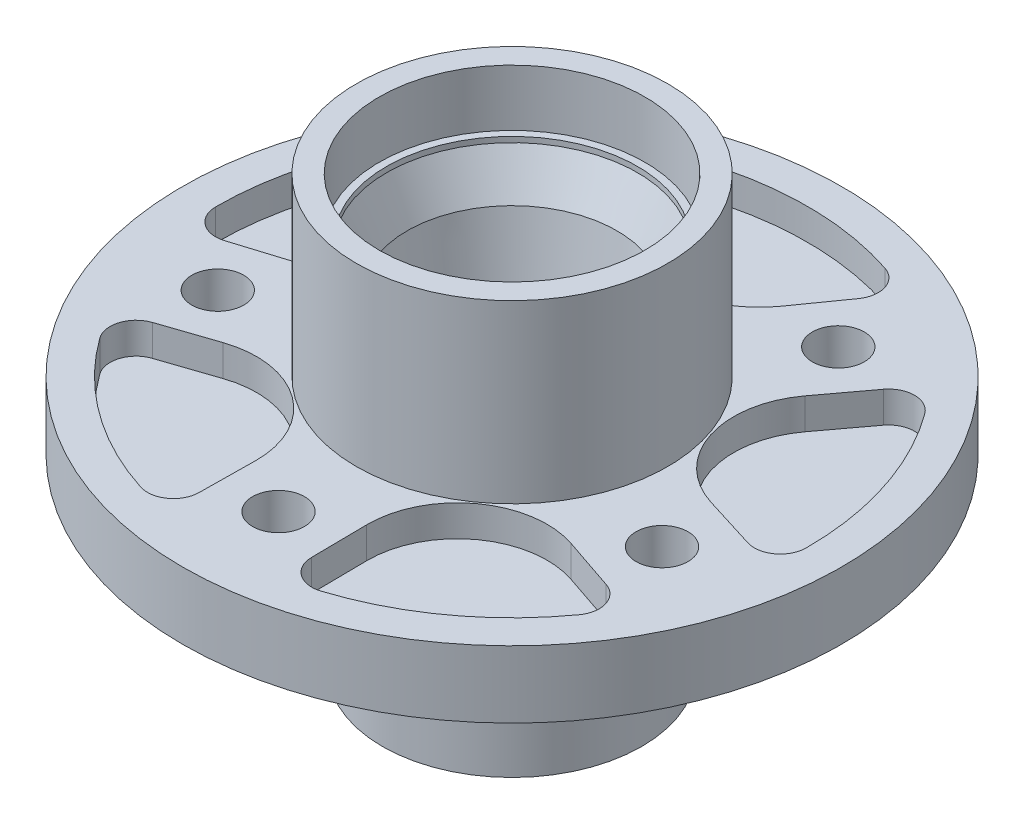
from build123d import *

# Parameters (mm, degrees)
SKETCH2_R          = 6.35
CUT_EXTRUDE1_DEPTH = 131.044155217
CIRPATTERN1_COUNT  = 5
CUT_EXTRUDE2_DEPTH = 7.62
CIRPATTERN2_COUNT  = 5
SKETCH5_R          = 1.1811
CUT_EXTRUDE3_DEPTH = 12.7
CIRPATTERN3_COUNT  = 6


with BuildPart() as part:
    # Sketch1 → Revolve1 (revolve)
    with BuildSketch(Plane.XY):
        Polygon((32.512, 43.053), (38.1, 43.053), (38.1, 0), (80.645, 0), (80.645, -16.383), (31.75, -16.383), (31.75, -62.484), (25.146, -62.484), (25.146, -49.577453141), (20.297971433, -41.110550681), (22.452839799, -41.110550681), (22.452839799, -6.400010137), (26.604598141, 18.108781172), (25.668560718, 18.108781172), (30.723038212, 27.881202719), (30.723038212, 29.21), (32.512, 29.21), align=None)
    revolve(axis=Axis((0, 66.608222053, 0), (0, -1, 0)))

    # Sketch2 → Cut-Extrude1 (cut, through all)
    with BuildSketch(Plane(origin=(0, 0, 0), x_dir=(1, 0, 0), z_dir=(0, 1, 0))):
        with Locations((0, -57.15)):
            Circle(SKETCH2_R)
    cut_extrude1 = extrude(amount=-CUT_EXTRUDE1_DEPTH, mode=Mode.SUBTRACT)

    # CirPattern1: Cut-Extrude1 ×5 about axis
    cirpattern1_axis = Axis((0, 48.32985, 0), (0, -1, 0))
    for i in range(1, CIRPATTERN1_COUNT):
        add(cut_extrude1.rotate(cirpattern1_axis, i * 360 / CIRPATTERN1_COUNT), mode=Mode.SUBTRACT)

    # Sketch3 → Cut-Extrude2 (cut)
    with BuildSketch(Plane(origin=(0, 0, 0), x_dir=(1, 0, 0), z_dir=(0, 1, 0))):
        with BuildLine():
            Line((-25.816115671, 58.929202602), (-17.918089551, 47.780088903))
            ThreePointArc((-17.918089551, 47.780088903), (0, 38.514784655), (17.918089551, 47.780088903))
            Line((17.918089551, 47.780088903), (25.816115671, 58.929202602))
            ThreePointArc((25.816115671, 58.929202602), (26.666104709, 64.585415867), (22.622433381, 68.630654062))
            ThreePointArc((22.622433381, 68.630654062), (0, 72.263), (-22.622433381, 68.630654062))
            ThreePointArc((-22.622433381, 68.630654062), (-26.666104709, 64.585415867), (-25.816115671, 58.929202602))
        make_face()
    cut_extrude2 = extrude(amount=-CUT_EXTRUDE2_DEPTH, mode=Mode.SUBTRACT)

    # CirPattern2: Cut-Extrude2 ×5 about axis
    cirpattern2_axis = Axis((0, 48.32985, 0), (0, -1, 0))
    for i in range(1, CIRPATTERN2_COUNT):
        add(cut_extrude2.rotate(cirpattern2_axis, i * 360 / CIRPATTERN2_COUNT), mode=Mode.SUBTRACT)

    # Sketch5 → Cut-Extrude3 (cut)
    with BuildSketch(Plane.XZ.offset(62.484)):
        with Locations((0, 28.575)):
            Circle(SKETCH5_R)
    cut_extrude3 = extrude(amount=-CUT_EXTRUDE3_DEPTH, mode=Mode.SUBTRACT)

    # CirPattern3: Cut-Extrude3 ×6 about axis
    cirpattern3_axis = Axis((0, 66.608222053, 0), (0, 1, 0))
    for i in range(1, CIRPATTERN3_COUNT):
        add(cut_extrude3.rotate(cirpattern3_axis, i * 360 / CIRPATTERN3_COUNT), mode=Mode.SUBTRACT)


solid = part.part
